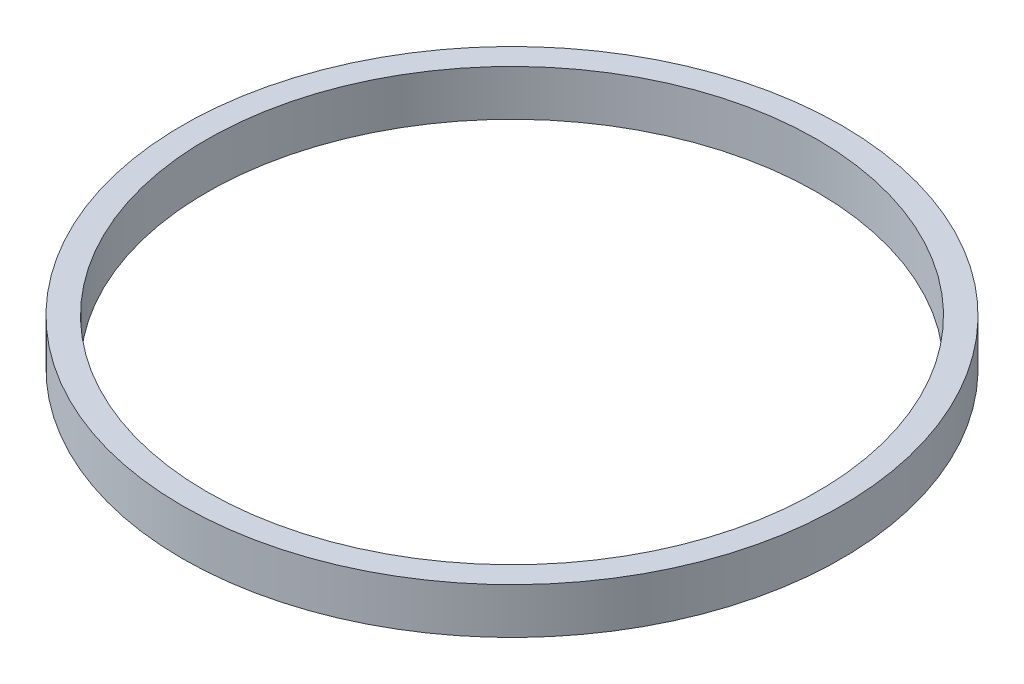
from build123d import *

# Parameters (mm, degrees)
SKETCH_1_R      = 108
SKETCH_1_R_2    = 100
EXTRUDE_1_DEPTH = 15


with BuildPart() as part:
    # 草图1 → 凸台-拉伸1 (new body)
    with BuildSketch(Plane(origin=(0, 0, 0), x_dir=(1, 0, 0), z_dir=(0, 1, 0))):
        with Locations((-71.710557533, 45.355395363)):
            Circle(SKETCH_1_R)
        with Locations((-71.710557533, 45.355395363)):
            Circle(SKETCH_1_R_2, mode=Mode.SUBTRACT)
    extrude(amount=EXTRUDE_1_DEPTH)


solid = part.part
